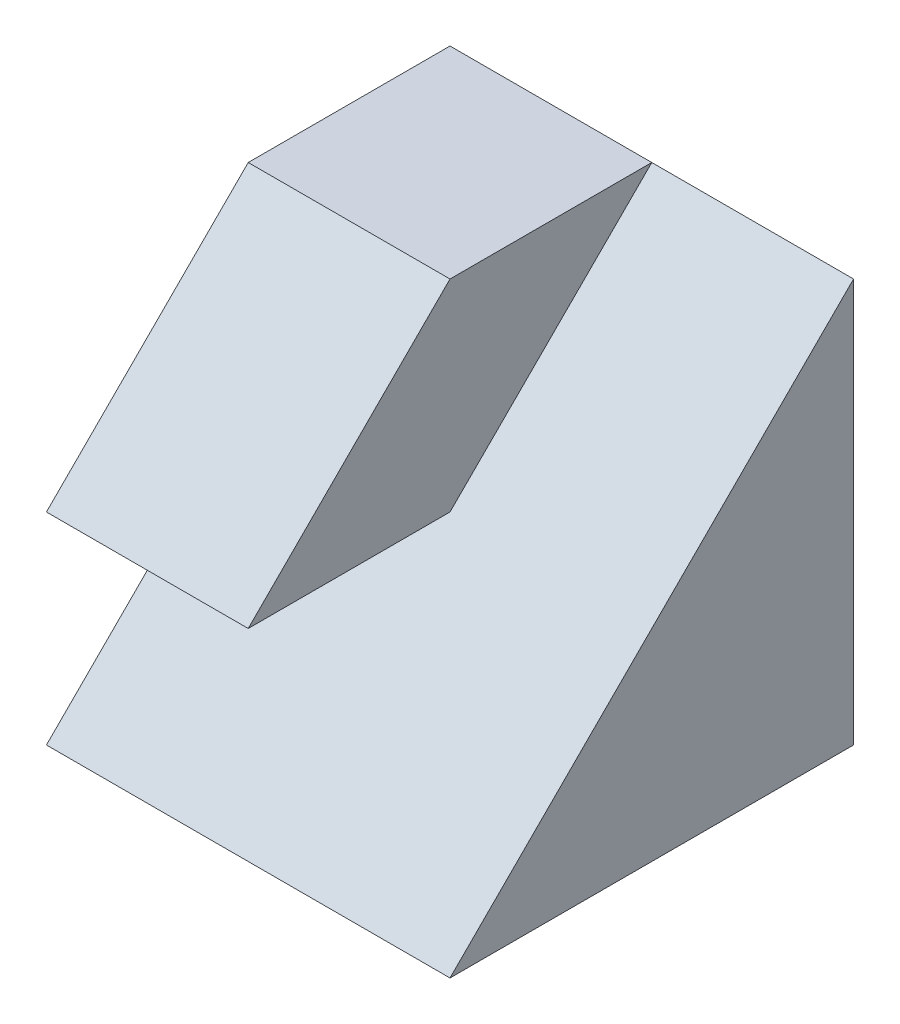
from build123d import *

# Parameters (mm, degrees)
SKETCH1_W           = 4
SKETCH1_H           = 4
BOSS_EXTRUDE1_DEPTH = 4
CUT_EXTRUDE1_DEPTH  = 10
CUT_EXTRUDE2_DEPTH  = 2


with BuildPart() as part:
    # Sketch1 → Boss-Extrude1 (new body)
    with BuildSketch(Plane(origin=(0, 0, 0), x_dir=(1, 0, 0), z_dir=(0, 1, 0))):
        Rectangle(SKETCH1_W, SKETCH1_H)
    extrude(amount=BOSS_EXTRUDE1_DEPTH)

    # Sketch2 → Cut-Extrude1 (cut)
    with BuildSketch(Plane.ZY.offset(2)):
        Polygon((0, 2), (2, 0), (2, 2), align=None)
        Polygon((0, 4), (2, 2), (2, 4), align=None)
    extrude(amount=-CUT_EXTRUDE1_DEPTH, mode=Mode.SUBTRACT)

    # Sketch3 → Cut-Extrude2 (cut)
    with BuildSketch(Plane(origin=(2, 0, 0), x_dir=(0, 0, -1), z_dir=(1, 0, 0))):
        Polygon((-2, 0), (2, 4), (-2, 4.116557223), align=None)
    extrude(amount=-CUT_EXTRUDE2_DEPTH, mode=Mode.SUBTRACT)


solid = part.part
